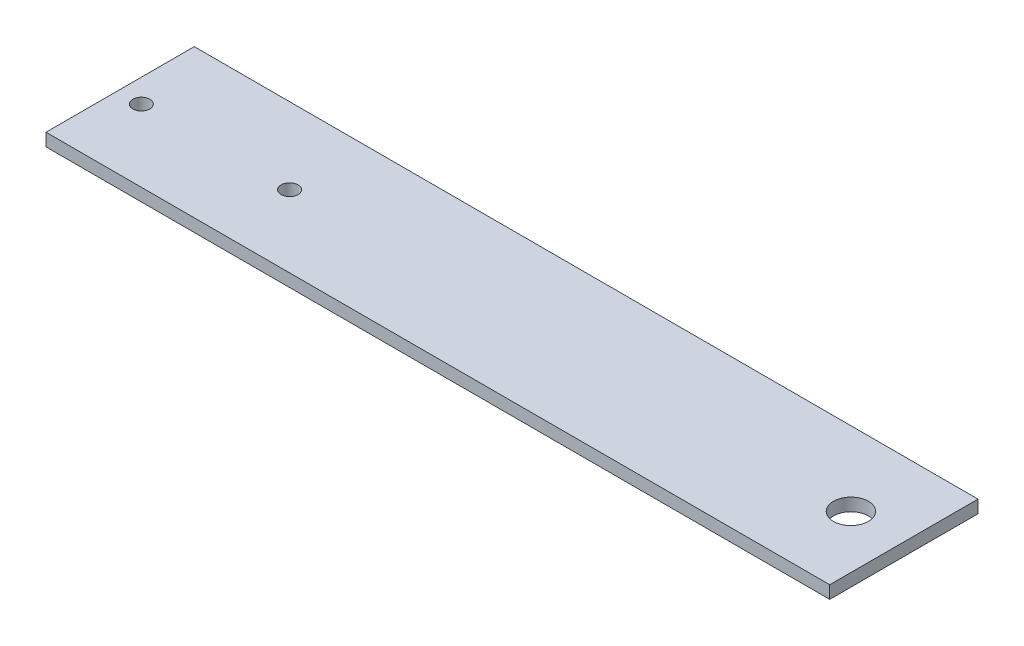
from build123d import *

# Parameters (mm, degrees)
SKETCH1_W           = 185
SKETCH1_H           = 35
SKETCH1_R           = 4.125
BOSS_EXTRUDE1_DEPTH = 3
SKETCH2_R           = 2
CUT_EXTRUDE1_DEPTH  = 4


with BuildPart() as part:
    # Sketch1 → Boss-Extrude1 (new body)
    with BuildSketch(Plane(origin=(0, 0, 0), x_dir=(1, 0, 0), z_dir=(0, 1, 0))):
        Rectangle(SKETCH1_W, SKETCH1_H)
        with Locations((80, 0)):
            Circle(SKETCH1_R, mode=Mode.SUBTRACT)
    extrude(amount=BOSS_EXTRUDE1_DEPTH)

    # Sketch2 → Cut-Extrude1 (cut, through all)
    with BuildSketch(Plane(origin=(0, 3, 0), x_dir=(1, 0, 0), z_dir=(0, 1, 0))):
        with Locations((-87, -0.5)):
            Circle(SKETCH2_R)
        with Locations((-52, -0.5)):
            Circle(SKETCH2_R)
    extrude(amount=-CUT_EXTRUDE1_DEPTH, mode=Mode.SUBTRACT)


solid = part.part
